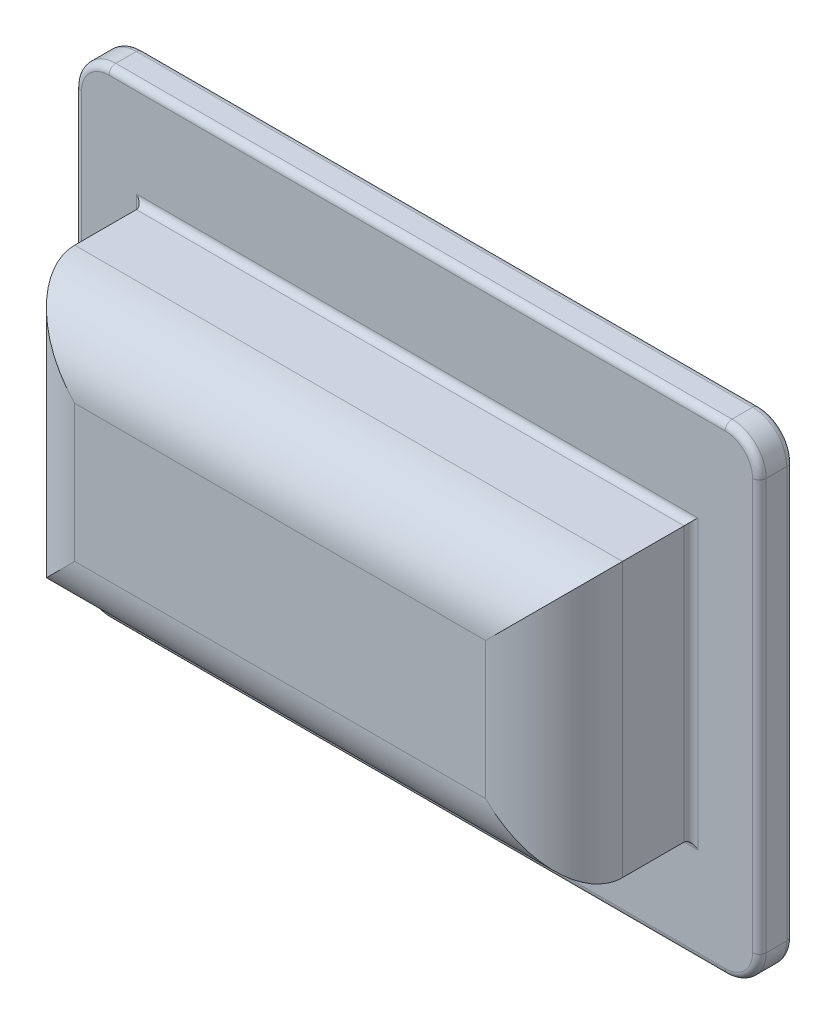
from build123d import *

# Parameters (mm, degrees)
SKETCH1_W           = 40
SKETCH1_H           = 20
BOSS_EXTRUDE1_DEPTH = 10
SKETCH2_W           = 32
SKETCH2_H           = 12
CUT_EXTRUDE1_DEPTH  = 5
FILLET1_R           = 5
SKETCH3_W           = 32
SKETCH3_H           = 12
BOSS_EXTRUDE2_DEPTH = 2.5
FILLET2_R           = 1
FILLET3_R           = 2
SMOOTHINGFILLET_R   = 0.5


with BuildPart() as part:
    # Sketch1 → Boss-Extrude1 (new body)
    with BuildSketch(Plane.XY):
        Rectangle(SKETCH1_W, SKETCH1_H)
    extrude(amount=BOSS_EXTRUDE1_DEPTH)

    # Sketch2 → Cut-Extrude1 (cut)
    with BuildSketch(Plane.XY):
        Rectangle(SKETCH2_W, SKETCH2_H)
    extrude(amount=CUT_EXTRUDE1_DEPTH, mode=Mode.SUBTRACT)

    # Fillet1
    fillet1_edges = [part.edges().sort_by_distance(p)[0] for p in [
        (-20, 0, 10),
        (0, -10, 10),
        (20, 0, 10),
        (0, 10, 10),
    ]]
    fillet(fillet1_edges, radius=FILLET1_R)

    # Sketch3 → Boss-Extrude2 (add)
    with BuildSketch(Plane.XY):
        with BuildLine():
            Line((22.5, 17.5), (-22.5, 17.5))
            ThreePointArc((-22.5, 17.5), (-24.267766953, 16.767766953), (-25, 15))
            Line((-25, 15), (-25, -15))
            ThreePointArc((-25, -15), (-24.267766953, -16.767766953), (-22.5, -17.5))
            Line((-22.5, -17.5), (22.5, -17.5))
            ThreePointArc((22.5, -17.5), (24.267766953, -16.767766953), (25, -15))
            Line((25, -15), (25, 15))
            ThreePointArc((25, 15), (24.267766953, 16.767766953), (22.5, 17.5))
        make_face()
        Rectangle(SKETCH3_W, SKETCH3_H, mode=Mode.SUBTRACT)
    extrude(amount=-BOSS_EXTRUDE2_DEPTH)

    # Fillet2
    fillet2_edges = [part.edges().sort_by_distance(p)[0] for p in [
        (16, 0, 5),
        (0, 6, 5),
        (-16, 0, 5),
        (0, -6, 5),
    ]]
    fillet(fillet2_edges, radius=FILLET2_R)

    # Fillet3
    fillet3_edges = [part.edges().sort_by_distance(p)[0] for p in [
        (0, -6, -2.5),
        (16, 0, -2.5),
        (0, 6, -2.5),
        (-16, 0, -2.5),
    ]]
    fillet(fillet3_edges, radius=FILLET3_R)

    # SmoothingFillet
    smoothingfillet_edges = [part.edges().sort_by_distance(p)[0] for p in [
        (24.267766953, 16.767766953, 0),
        (0, 17.5, 0),
        (-24.267766953, 16.767766953, 0),
        (-25, 0, 0),
        (-24.267766953, -16.767766953, 0),
        (0, -17.5, 0),
        (24.267766953, -16.767766953, 0),
        (25, 0, 0),
        (24.267766953, 16.767766953, -2.5),
        (25, 0, -2.5),
        (24.267766953, -16.767766953, -2.5),
        (0, -17.5, -2.5),
        (-24.267766953, -16.767766953, -2.5),
        (-25, 0, -2.5),
        (-24.267766953, 16.767766953, -2.5),
        (0, 17.5, -2.5),
        (0, -10, 0),
        (-20, 0, 0),
        (0, 10, 0),
        (20, 0, 0),
    ]]
    fillet(smoothingfillet_edges, radius=SMOOTHINGFILLET_R)


solid = part.part
